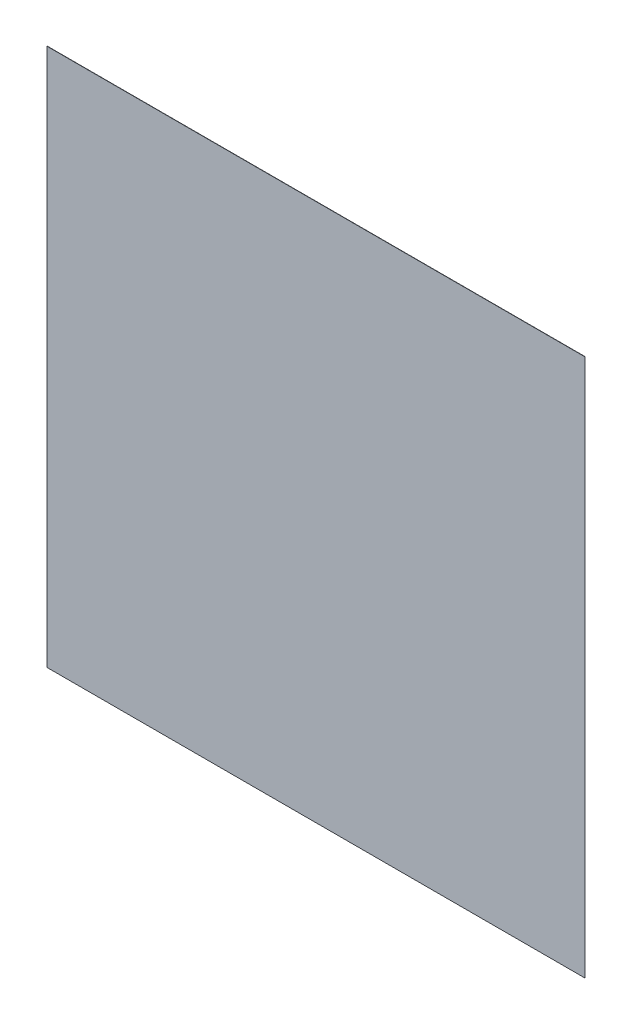
from build123d import *

# Parameters (mm, degrees)
SKETCH1_W           = 203.2
SKETCH1_H           = 203.2
BOSS_EXTRUDE1_DEPTH = 0.1


with BuildPart() as part:
    # Sketch1 → Boss-Extrude1 (new body)
    with BuildSketch(Plane.XY):
        Rectangle(SKETCH1_W, SKETCH1_H)
    extrude(amount=-BOSS_EXTRUDE1_DEPTH)


solid = part.part
